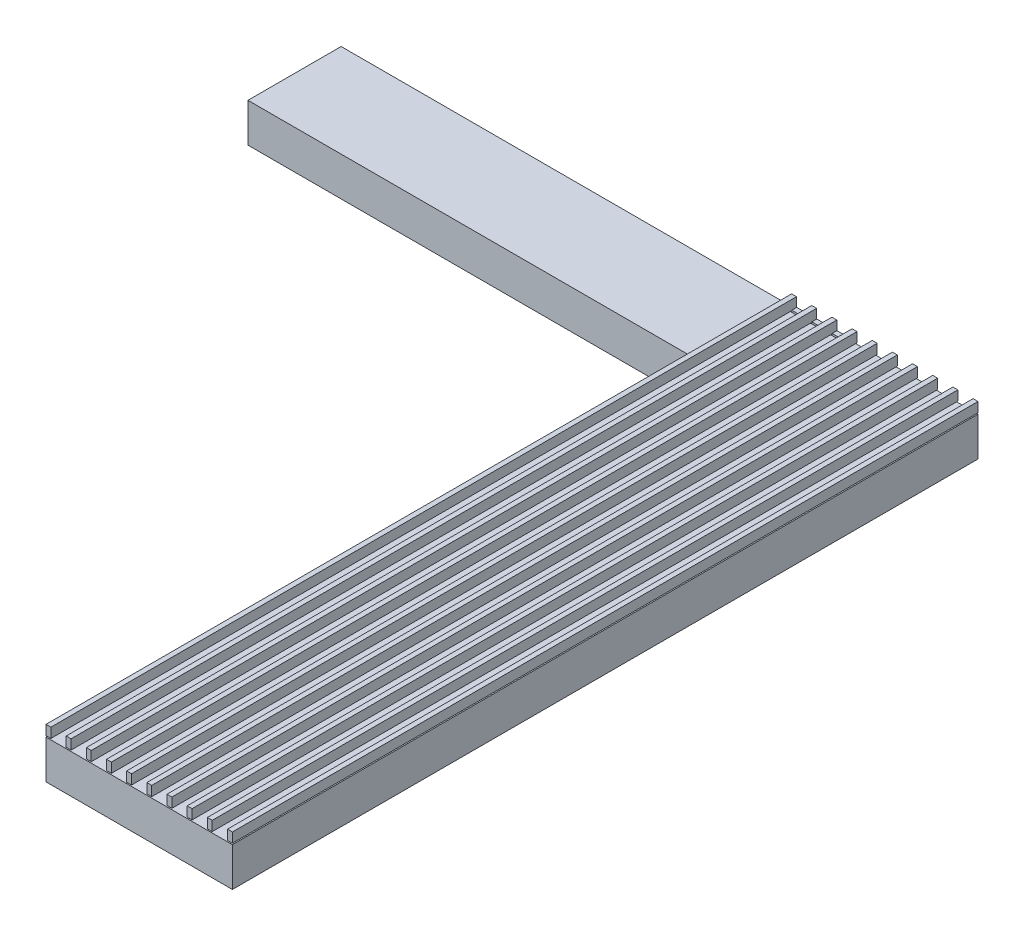
from build123d import *

# Parameters (mm, degrees)
SKETCH1_W           = 609.6
SKETCH1_H           = 2438.4
BOSS_EXTRUDE1_DEPTH = 127
SKETCH2_W           = 16
SKETCH2_H           = 2438.4
BOSS_EXTRUDE2_DEPTH = 32
LPATTERN2_COUNT     = 10
LPATTERN2_PITCH     = 65.955555556
SKETCH3_W           = 304.8
SKETCH3_H           = 127
BOSS_EXTRUDE3_DEPTH = 1473.2
BOSS_EXTRUDE4_DEPTH = 16
SKETCH5_R           = 2
CUT_EXTRUDE1_DEPTH  = 6
SKETCH6_R           = 4
CUT_EXTRUDE2_DEPTH  = 3


with BuildPart() as part:
    # Sketch1 → Boss-Extrude1 (new body)
    with BuildSketch(Plane(origin=(0, 0, 0), x_dir=(1, 0, 0), z_dir=(0, 1, 0))):
        with Locations((304.8, 1219.2)):
            Rectangle(SKETCH1_W, SKETCH1_H)
    extrude(amount=BOSS_EXTRUDE1_DEPTH)


with BuildPart() as body_2:
    # Sketch2 → Boss-Extrude2 (new body)
    with BuildSketch(Plane(origin=(0, 131, 0), x_dir=(1, 0, 0), z_dir=(0, 1, 0))):
        with Locations((8, 1219.2)):
            Rectangle(SKETCH2_W, SKETCH2_H)
    boss_extrude2 = extrude(amount=BOSS_EXTRUDE2_DEPTH)


with BuildPart() as lpattern2_1:
    # LPattern2: Boss-Extrude2 ×10
    with Locations(*[(i * LPATTERN2_PITCH, 0, 0) for i in range(1, LPATTERN2_COUNT)]):
        add(boss_extrude2)


with BuildPart() as body_12:
    # Sketch3 → Boss-Extrude3 (new body)
    with BuildSketch(Plane.ZY):
        with Locations((-2286, 63.5)):
            Rectangle(SKETCH3_W, SKETCH3_H)
    extrude(amount=BOSS_EXTRUDE3_DEPTH)


with BuildPart() as body_13:
    # Sketch4 → Boss-Extrude4 (new body)
    with BuildSketch(Plane(origin=(0, 0, -2438.4), x_dir=(-1, 0, 0), z_dir=(0, 0, -1))):
        Polygon((0, 130), (-16.5, 130), (-16.5, 133), (-65.455555556, 133), (-65.455555556, 130), (-65.955555556, 130), (-82.455555556, 130), (-82.455555556, 133), (-131.411111111, 133), (-131.411111111, 130), (-131.911111111, 130), (-148.411111111, 130), (-148.411111111, 133), (-197.366666667, 133), (-197.366666667, 130), (-197.866666667, 130), (-197.866666667, 127), (0, 127), align=None)
    extrude(amount=-BOSS_EXTRUDE4_DEPTH)

    # Sketch5 → Cut-Extrude1 (cut)
    with BuildSketch(Plane(origin=(0, 133, 0), x_dir=(1, 0, 0), z_dir=(0, 1, 0))):
        with Locations((106.933333333, 2430.4)):
            Circle(SKETCH5_R)
    extrude(amount=-CUT_EXTRUDE1_DEPTH, mode=Mode.SUBTRACT)

    # Sketch6 → Cut-Extrude2 (cut)
    with BuildSketch(Plane(origin=(0, 133, 0), x_dir=(1, 0, 0), z_dir=(0, 1, 0))):
        with Locations((106.933333333, 2430.4)):
            Circle(SKETCH6_R)
    extrude(amount=-CUT_EXTRUDE2_DEPTH, mode=Mode.SUBTRACT)


solid = Compound([part.part, body_2.part, lpattern2_1.part, body_12.part, body_13.part])
